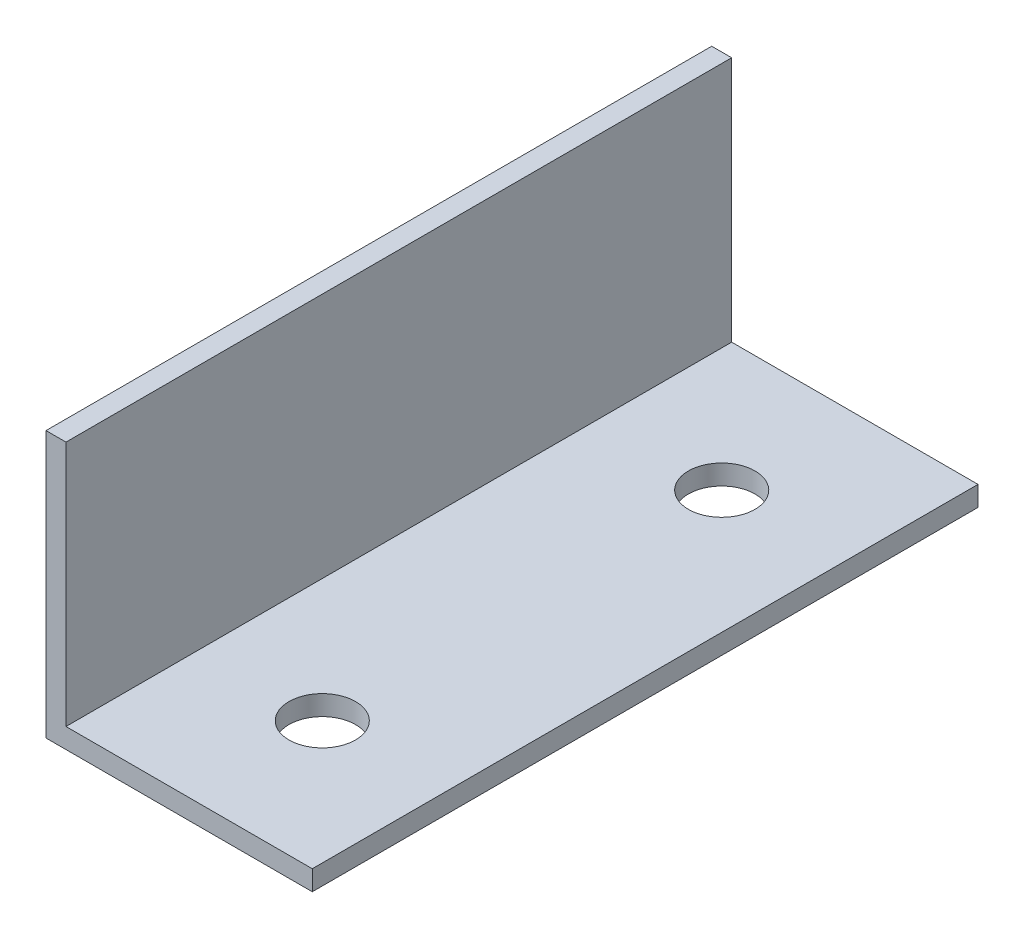
from build123d import *

# Parameters (mm, degrees)
EXTRUDE_1_DEPTH     = 100
CUT_EXTRUDE_1_REACH = 5
SKETCH_2_R          = 5


with BuildPart() as part:
    # Эскиз1 → Бобышка-Вытянуть1 (new body)
    with BuildSketch(Plane.XY):
        Polygon((0, 0), (0, 40), (3, 40), (3, 3), (40, 3), (40, 0), align=None)
    extrude(amount=EXTRUDE_1_DEPTH)

    # Эскиз2 → Вырез-Вытянуть1 (cut, up to next)
    with BuildSketch(Plane(origin=(0, 3, 0), x_dir=(1, 0, 0), z_dir=(0, 1, 0)), mode=Mode.PRIVATE) as cut_extrude_1_sk1:
        with Locations((21.5, -20)):
            Circle(SKETCH_2_R)
    cut_extrude_1_tool1 = extrude(cut_extrude_1_sk1.sketch, amount=-CUT_EXTRUDE_1_REACH, mode=Mode.PRIVATE) & part.part
    add(cut_extrude_1_tool1.solids().sort_by_distance((21.5, 3, 20))[0], mode=Mode.SUBTRACT)
    # Эскиз2 → Вырез-Вытянуть1 (cut, up to next)
    with BuildSketch(Plane(origin=(0, 3, 0), x_dir=(1, 0, 0), z_dir=(0, 1, 0)), mode=Mode.PRIVATE) as cut_extrude_1_sk2:
        with Locations((21.5, -80)):
            Circle(SKETCH_2_R)
    cut_extrude_1_tool2 = extrude(cut_extrude_1_sk2.sketch, amount=-CUT_EXTRUDE_1_REACH, mode=Mode.PRIVATE) & part.part
    add(cut_extrude_1_tool2.solids().sort_by_distance((21.5, 3, 80))[0], mode=Mode.SUBTRACT)


solid = part.part
